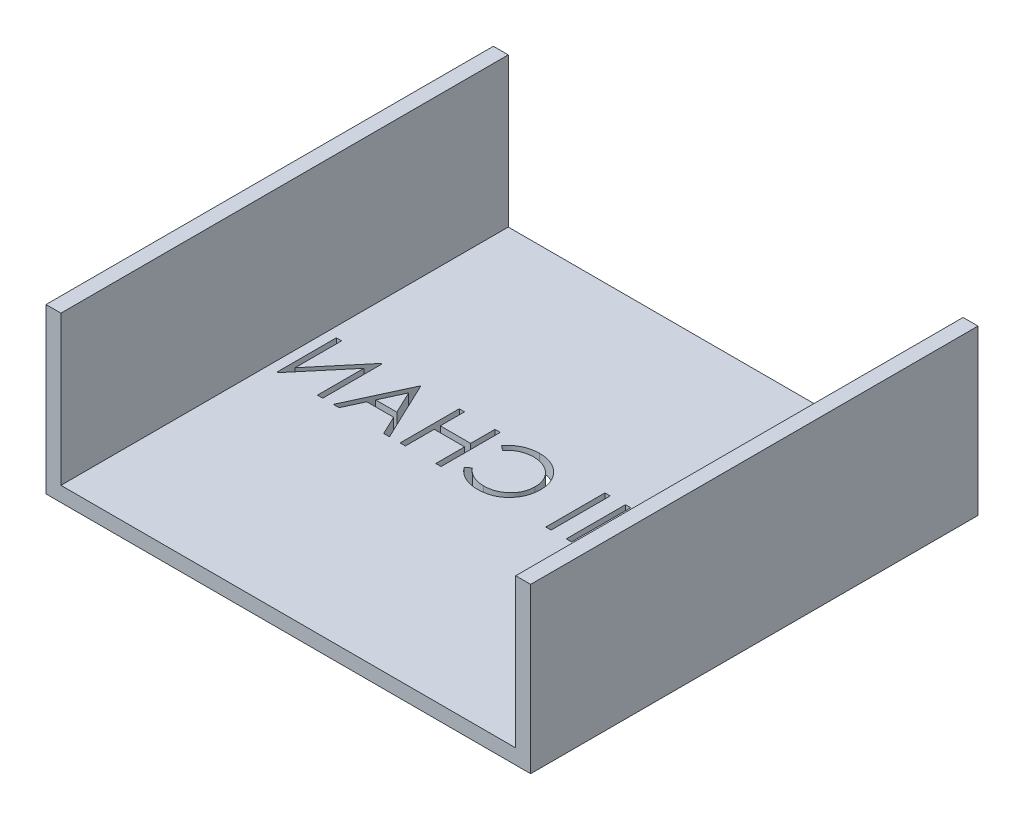
from build123d import *

# Parameters (mm, degrees)
SKETCH1_W           = 65
SKETCH1_H           = 60
BOSS_EXTRUDE1_DEPTH = 2
BOSS_EXTRUDE2_DEPTH = 20
SKETCH4_W           = 0.712339743
SKETCH4_H           = 7.9375
SKETCH4_W_2         = 0.712339744
CUT_EXTRUDE1_DEPTH  = 20


with BuildPart() as part:
    # Sketch1 → Boss-Extrude1 (new body)
    with BuildSketch(Plane(origin=(0, 0, 0), x_dir=(1, 0, 0), z_dir=(0, 1, 0))):
        Rectangle(SKETCH1_W, SKETCH1_H)
    extrude(amount=BOSS_EXTRUDE1_DEPTH)

    # Sketch3 → Boss-Extrude2 (add)
    with BuildSketch(Plane(origin=(0, 2, 0), x_dir=(1, 0, 0), z_dir=(0, 1, 0))):
        Polygon((-30.5, 30), (-32.5, 30), (-32.5, -30), (-30.5, -30), (-30.5, 0), align=None)
        Polygon((32.5, 30), (30.5, 30), (30.5, 0), (30.5, -30), (32.5, -30), align=None)
    extrude(amount=BOSS_EXTRUDE2_DEPTH)

    # Sketch4 → Cut-Extrude1 (cut)
    with BuildSketch(Plane(origin=(0, 0, 0), x_dir=(-1, 0, 0), z_dir=(0, -1, 0))):
        with BuildLine():
            add(Edge.make_bspline(
                [(-24.309282093, 5.81367782), (-24.162306567, 5.809955179), (-23.873634508, 5.802643606), (-23.449375365, 5.746674924), (-23.044347203, 5.649847879), (-22.655250638, 5.520890758), (-22.28673978, 5.348863849), (-21.936040863, 5.14093503), (-21.60398831, 4.894925918), (-21.295057677, 4.612738207), (-21.012353522, 4.305707874), (-20.763284101, 3.978052614), (-20.554545328, 3.631753544), (-20.383127561, 3.267851304), (-20.248646785, 2.887168876), (-20.15584824, 2.487676763), (-20.096570649, 2.071963376), (-20.089640582, 1.788420308), (-20.086125042, 1.644582267)],
                knots=[0, 0, 0, 0, 0.000440855, 0.000865876, 0.001280862, 0.001688649, 0.002093439, 0.002498389, 0.0029099, 0.003330887, 0.003751771, 0.004160416, 0.004563453, 0.004962482, 0.00536529, 0.005772174, 0.006191104, 0.006622429, 0.006622429, 0.006622429, 0.006622429], degree=3))
            add(Edge.make_bspline(
                [(-20.086125042, 1.644582267), (-20.089640067, 1.501803773), (-20.09656859, 1.220370819), (-20.155915639, 0.807295508), (-20.248990764, 0.410214822), (-20.381878725, 0.029791645), (-20.552479363, -0.33437533), (-20.762608055, -0.681327886), (-21.010124729, -1.011179767), (-21.291808124, -1.320317418), (-21.598878344, -1.603793825), (-21.928239842, -1.850806275), (-22.272485407, -2.063359201), (-22.636044923, -2.23295789), (-23.014096793, -2.368512066), (-23.410024561, -2.46093321), (-23.821972996, -2.520548468), (-24.102894737, -2.527394031), (-24.24568033, -2.530873462)],
                knots=[0, 0, 0, 0, 0.000428147, 0.000843928, 0.001249264, 0.001650047, 0.002050514, 0.002453552, 0.002864737, 0.003285724, 0.003706608, 0.004116522, 0.004519026, 0.004918054, 0.005317864, 0.005721654, 0.00613586, 0.006564007, 0.006564007, 0.006564007, 0.006564007], degree=3))
            add(Edge.make_bspline(
                [(-24.24568033, -2.530873462), (-24.389517625, -2.527359674), (-24.673059222, -2.520433063), (-25.089294999, -2.461057377), (-25.489067739, -2.368208348), (-25.871234214, -2.235517306), (-26.236007537, -2.064028229), (-26.584101117, -1.854921869), (-26.914117755, -1.606802102), (-27.223321358, -1.325210049), (-27.506234718, -1.01866028), (-27.752885445, -0.69019688), (-27.962038827, -0.346263969), (-28.132952099, 0.014092916), (-28.26826257, 0.389131723), (-28.360575282, 0.781354163), (-28.420301459, 1.188524114), (-28.427184057, 1.465753544), (-28.430676324, 1.606421209)],
                knots=[0, 0, 0, 0, 0.000431324, 0.000850255, 0.001258686, 0.00166097, 0.002061437, 0.002465837, 0.002877022, 0.003298009, 0.003718893, 0.004126581, 0.004528258, 0.004924412, 0.005321226, 0.005721923, 0.006131405, 0.006553199, 0.006553199, 0.006553199, 0.006553199], degree=3))
            add(Edge.make_bspline(
                [(-28.430676324, 1.606421209), (-28.429463847, 1.700838155), (-28.427054189, 1.888480935), (-28.398044458, 2.167124832), (-28.355949171, 2.441287574), (-28.295619834, 2.710189545), (-28.216717303, 2.973172493), (-28.12361717, 3.232050116), (-28.009907163, 3.484198918), (-27.881363551, 3.730813395), (-27.737894808, 3.968049182), (-27.57942659, 4.192293951), (-27.411524951, 4.405429425), (-27.227457969, 4.601932452), (-27.033292102, 4.787519494), (-26.825877566, 4.959338513), (-26.606479976, 5.118938848), (-26.374155293, 5.262767122), (-26.134628134, 5.392849445), (-25.887711156, 5.504477571), (-25.63675786, 5.600285604), (-25.380592855, 5.677938904), (-25.11989639, 5.7392437), (-24.854099485, 5.780988948), (-24.583413894, 5.810072669), (-24.401052509, 5.812470933), (-24.309282093, 5.81367782)],
                knots=[0, 0, 0, 0, 0.000283139, 0.000562707, 0.000839544, 0.00111497, 0.001388652, 0.001662791, 0.001939668, 0.002217749, 0.002496714, 0.002770654, 0.003041079, 0.003309984, 0.00357766, 0.003846392, 0.004117372, 0.00439092, 0.004665533, 0.004934509, 0.00520324, 0.005470831, 0.005736958, 0.006005943, 0.006277599, 0.006552792, 0.006552792, 0.006552792, 0.006552792], degree=3))
        make_face()
        with BuildLine():
            add(Edge.make_bspline(
                [(-24.274301123, 4.999575256), (-24.349627167, 4.998657022), (-24.499559133, 4.996829334), (-24.722454421, 4.972754408), (-24.942418271, 4.938441981), (-25.15949611, 4.889498175), (-25.372779659, 4.822813984), (-25.584256977, 4.746067639), (-25.791999617, 4.652584094), (-25.995321759, 4.546963854), (-26.192432733, 4.430058265), (-26.378425824, 4.300854437), (-26.553782535, 4.162382358), (-26.718073514, 4.01431887), (-26.870816351, 3.855909952), (-27.015017371, 3.689557105), (-27.1448966, 3.510505495), (-27.263926391, 3.323610465), (-27.370442743, 3.129115451), (-27.465160601, 2.929068085), (-27.542639692, 2.721836545), (-27.605827581, 2.509669081), (-27.658214652, 2.292901717), (-27.691402301, 2.06989006), (-27.71574176, 1.841754716), (-27.71746498, 1.687581583), (-27.71833658, 1.609601297)],
                knots=[0, 0, 0, 0, 0.000225876, 0.000449592, 0.000671789, 0.000893582, 0.001116398, 0.00134177, 0.001568115, 0.001799246, 0.002028852, 0.00225512, 0.002478117, 0.002698773, 0.002918043, 0.003137935, 0.003358648, 0.003580965, 0.003802278, 0.0040235, 0.004244401, 0.004465235, 0.004687386, 0.004912724, 0.005141187, 0.00537501, 0.00537501, 0.00537501, 0.00537501], degree=3))
            add(Edge.make_bspline(
                [(-27.71833658, 1.609601297), (-27.715445375, 1.494933404), (-27.709757481, 1.269346183), (-27.659960849, 0.938764857), (-27.583257443, 0.621064636), (-27.470188058, 0.317983878), (-27.328785771, 0.026917379), (-27.154099788, -0.249552787), (-26.947137219, -0.511501341), (-26.71204315, -0.75709954), (-26.45504344, -0.981267704), (-26.182145999, -1.17803472), (-25.896274425, -1.344518679), (-25.596683233, -1.48014804), (-25.28497185, -1.587621195), (-24.959131689, -1.661278091), (-24.621333326, -1.70975457), (-24.391076304, -1.714409927), (-24.274301123, -1.716770898)],
                knots=[0, 0, 0, 0, 0.000343817, 0.000676395, 0.001000721, 0.001322681, 0.001644817, 0.001969941, 0.002301712, 0.002644723, 0.002988456, 0.003323386, 0.003652556, 0.003979169, 0.004308524, 0.004639841, 0.004980069, 0.005330172, 0.005330172, 0.005330172, 0.005330172], degree=3))
            add(Edge.make_bspline(
                [(-24.274301123, -1.716770898), (-24.195811718, -1.715692522), (-24.040143653, -1.713553779), (-23.808605594, -1.692012137), (-23.581238828, -1.657468433), (-23.358362265, -1.607732839), (-23.140228853, -1.545486496), (-22.925928139, -1.471536827), (-22.71774273, -1.379277668), (-22.513046313, -1.277342135), (-22.317111979, -1.161136778), (-22.130069254, -1.036318117), (-21.956632657, -0.898049995), (-21.792464584, -0.752186385), (-21.639094646, -0.59578623), (-21.497559986, -0.42905287), (-21.368337186, -0.250933879), (-21.249352595, -0.064322334), (-21.143209481, 0.130704882), (-21.05072831, 0.331477545), (-20.972269261, 0.537501275), (-20.908931402, 0.749073231), (-20.859298302, 0.965791585), (-20.825099197, 1.187946512), (-20.801176846, 1.415093592), (-20.799373724, 1.56872698), (-20.798464785, 1.646172311)],
                knots=[0, 0, 0, 0, 0.000235412, 0.000466894, 0.000696945, 0.000924943, 0.001151434, 0.001377226, 0.001604385, 0.001834068, 0.002062863, 0.002287335, 0.0025081, 0.002727693, 0.002945825, 0.003164685, 0.003383176, 0.003605493, 0.003828201, 0.004048753, 0.004268168, 0.004489001, 0.004710793, 0.004934561, 0.005163024, 0.005395258, 0.005395258, 0.005395258, 0.005395258], degree=3))
            add(Edge.make_bspline(
                [(-20.798464785, 1.646172311), (-20.799374452, 1.72308783), (-20.801178944, 1.875663929), (-20.825087771, 2.101226856), (-20.859334433, 2.321783247), (-20.908689146, 2.536467229), (-20.972302887, 2.745333527), (-21.050742011, 2.948185972), (-21.143237244, 3.145780272), (-21.24939161, 3.337628052), (-21.368716781, 3.521720762), (-21.499105512, 3.697711947), (-21.642809069, 3.862296557), (-21.795721661, 4.019537738), (-21.961662776, 4.166081881), (-22.139880729, 4.301977597), (-22.328211926, 4.430504487), (-22.527618335, 4.546449958), (-22.733412659, 4.653525093), (-22.944581814, 4.745262189), (-23.158733522, 4.823213246), (-23.375323205, 4.889699934), (-23.596173888, 4.938250288), (-23.819793286, 4.97278533), (-24.045872015, 4.996820955), (-24.19791646, 4.998654242), (-24.274301123, 4.999575256)],
                knots=[0, 0, 0, 0, 0.000230644, 0.000457525, 0.000679722, 0.000899965, 0.001117754, 0.001334199, 0.001551867, 0.001771788, 0.001991427, 0.002209582, 0.002428269, 0.002646401, 0.002867182, 0.003091711, 0.003318391, 0.003550734, 0.003783277, 0.004013987, 0.004240851, 0.00446671, 0.004693156, 0.004918494, 0.005145375, 0.00537443, 0.00537443, 0.00537443, 0.00537443], degree=3))
        make_face(mode=Mode.SUBTRACT)
        Polygon((-18.457919914, -2.327347821), (-18.457919914, 5.610152179), (-18.308455771, 5.610152179), (-13.064490426, -0.637130974), (-13.064490426, 5.610152179), (-12.352150683, 5.610152179), (-12.352150683, -2.327347821), (-12.514335178, -2.327347821), (-17.74558017, 3.905624935), (-17.74558017, -2.327347821), align=None)
        with Locations((-9.960724401, 1.641402179)):
            Rectangle(SKETCH4_W, SKETCH4_H)
        with Locations((-7.213128247, 1.641402179)):
            Rectangle(SKETCH4_W_2, SKETCH4_H)
        with BuildLine():
            Line((5.558105728, 4.15367181), (4.934808452, 3.676658589))
            add(Edge.make_bspline(
                [(4.934808452, 3.676658589), (4.890345098, 3.729649271), (4.802017852, 3.834916205), (4.659915732, 3.9827341), (4.511820935, 4.121221389), (4.357790071, 4.251037795), (4.195050639, 4.367643674), (4.027544899, 4.47711564), (3.852470761, 4.575240689), (3.610373077, 4.694219246), (3.293671707, 4.818375705), (2.894994126, 4.922477676), (2.47881717, 4.988747128), (2.1948869, 4.995924536), (2.050468508, 4.999575256)],
                knots=[0, 0, 0, 0, 0.000207475, 0.000412153, 0.000614644, 0.000815582, 0.001015953, 0.001214861, 0.001415635, 0.00161759, 0.002023886, 0.002433479, 0.002851754, 0.00328474, 0.00328474, 0.00328474, 0.00328474], degree=3))
            add(Edge.make_bspline(
                [(2.050468508, 4.999575256), (1.970904597, 4.998659126), (1.812515203, 4.99683537), (1.577455272, 4.97277539), (1.346784603, 4.938958896), (1.120653242, 4.888781824), (0.899349032, 4.82534392), (0.681425192, 4.749539856), (0.470036867, 4.655752987), (0.262259791, 4.552093183), (0.063189081, 4.435009514), (-0.125167903, 4.307298876), (-0.302124187, 4.17039039), (-0.467819754, 4.023770917), (-0.622423994, 3.868100756), (-0.764816645, 3.70172091), (-0.894504986, 3.525163302), (-1.014059668, 3.34075611), (-1.121131403, 3.149036476), (-1.210779522, 2.949294798), (-1.290166139, 2.744951564), (-1.352984064, 2.533698039), (-1.402705736, 2.317020695), (-1.437013115, 2.094338015), (-1.460799469, 1.866115206), (-1.462614156, 1.711426229), (-1.463528888, 1.633451958)],
                knots=[0, 0, 0, 0, 0.000238591, 0.000474968, 0.000708163, 0.000937714, 0.001169228, 0.001398548, 0.001629257, 0.001862496, 0.002094838, 0.002321519, 0.002544788, 0.00276557, 0.002984817, 0.003202467, 0.003421899, 0.003641538, 0.003861459, 0.004079904, 0.004297833, 0.004518666, 0.004740458, 0.004964226, 0.005194271, 0.005428094, 0.005428094, 0.005428094, 0.005428094], degree=3))
            add(Edge.make_bspline(
                [(-1.463528888, 1.633451958), (-1.460667263, 1.516132715), (-1.455048841, 1.285791942), (-1.405046369, 0.948401451), (-1.329061608, 0.625184922), (-1.215179854, 0.31816278), (-1.074756292, 0.023549182), (-0.897317763, -0.253671074), (-0.691812401, -0.517687212), (-0.455332914, -0.762259611), (-0.195876867, -0.985674667), (0.082497861, -1.182412593), (0.379097942, -1.346412415), (0.690648514, -1.482882866), (1.019547022, -1.587786516), (1.365202021, -1.661637296), (1.726861724, -1.709811527), (1.973988756, -1.714423641), (2.099759874, -1.716770898)],
                knots=[0, 0, 0, 0, 0.000351759, 0.000690633, 0.001021136, 0.001346082, 0.001671077, 0.001998395, 0.002331417, 0.00267328, 0.003017175, 0.003357288, 0.003693965, 0.0040322, 0.004376149, 0.004727635, 0.005091509, 0.005468621, 0.005468621, 0.005468621, 0.005468621], degree=3))
            add(Edge.make_bspline(
                [(2.099759874, -1.716770898), (2.238332044, -1.712940987), (2.511075223, -1.705402805), (2.911052711, -1.641541651), (3.293948108, -1.537996016), (3.65978201, -1.393084657), (4.007523083, -1.20470445), (4.337715509, -0.976336049), (4.650637999, -0.705807152), (4.838805014, -0.499243629), (4.934808452, -0.393854231)],
                knots=[0, 0, 0, 0, 0.000415516, 0.000817835, 0.001211659, 0.001603475, 0.001995472, 0.002395512, 0.002805811, 0.003233205, 0.003233205, 0.003233205, 0.003233205], degree=3))
            Line((4.934808452, -0.393854231), (5.558105728, -0.86609732))
            add(Edge.make_bspline(
                [(5.558105728, -0.86609732), (5.507945014, -0.930818452), (5.407863854, -1.059950706), (5.24580728, -1.241995476), (5.075089123, -1.413227842), (4.894441352, -1.572267269), (4.705942075, -1.722296146), (4.506206652, -1.859052085), (4.297860811, -1.984443912), (4.081610475, -2.099258545), (3.857685406, -2.201124444), (3.62635392, -2.288332096), (3.388613151, -2.363454613), (3.14445223, -2.425258113), (2.89336471, -2.473497892), (2.63625667, -2.505746083), (2.372573203, -2.527839354), (2.194679266, -2.52985302), (2.104530006, -2.530873462)],
                knots=[0, 0, 0, 0, 0.000245594, 0.000490011, 0.000730618, 0.000970546, 0.001211672, 0.001452924, 0.001696165, 0.001940846, 0.002187056, 0.002433641, 0.002682065, 0.002934662, 0.003188815, 0.003448558, 0.003711728, 0.00398211, 0.00398211, 0.00398211, 0.00398211], degree=3))
            add(Edge.make_bspline(
                [(2.104530006, -2.530873462), (2.019159547, -2.530279301), (1.850350036, -2.529104419), (1.601115367, -2.510072183), (1.358478282, -2.484105815), (1.123132255, -2.445007661), (0.89379299, -2.398869604), (0.672539522, -2.337022289), (0.45719467, -2.267741144), (0.248623612, -2.186313763), (0.046648935, -2.094428849), (-0.148077923, -1.990580135), (-0.335467403, -1.875640906), (-0.51736184, -1.752144722), (-0.691074217, -1.61612477), (-0.858109891, -1.469470081), (-1.019405506, -1.312674949), (-1.11919731, -1.199611264), (-1.169370735, -1.142764989)],
                knots=[0, 0, 0, 0, 0.000256042, 0.00050629, 0.000749484, 0.000987885, 0.001221767, 0.001450893, 0.001676663, 0.001900187, 0.002122185, 0.002341985, 0.00256178, 0.002781413, 0.003001196, 0.003223171, 0.003448048, 0.003675441, 0.003675441, 0.003675441, 0.003675441], degree=3))
            add(Edge.make_bspline(
                [(-1.169370735, -1.142764989), (-1.249733712, -1.044019792), (-1.409489454, -0.847721538), (-1.613881629, -0.529572974), (-1.788841263, -0.197404), (-1.930300941, 0.150530481), (-2.040887854, 0.513449734), (-2.117498778, 0.891536705), (-2.167281881, 1.284438288), (-2.172974858, 1.551675291), (-2.175868631, 1.687513457)],
                knots=[0, 0, 0, 0, 0.000381693, 0.000758779, 0.001132168, 0.001506572, 0.001883818, 0.002268629, 0.002662677, 0.003070039, 0.003070039, 0.003070039, 0.003070039], degree=3))
            add(Edge.make_bspline(
                [(-2.175868631, 1.687513457), (-2.172341675, 1.830287432), (-2.165402607, 2.111186314), (-2.106447857, 2.523423673), (-2.011608801, 2.918374167), (-1.876905143, 3.295300516), (-1.706123364, 3.656185259), (-1.495152294, 3.998271562), (-1.246442882, 4.323747162), (-0.961945719, 4.627673473), (-0.649962655, 4.905575219), (-0.315864631, 5.150064288), (0.039694427, 5.353530797), (0.412797412, 5.52361138), (0.806238154, 5.654340788), (1.219177224, 5.74585605), (1.650838691, 5.802818082), (1.945348121, 5.810019), (2.094989742, 5.81367782)],
                knots=[0, 0, 0, 0, 0.000428147, 0.000842353, 0.001246515, 0.001644827, 0.002040981, 0.002442129, 0.002848241, 0.003267871, 0.003689098, 0.00410001, 0.004507471, 0.004915936, 0.005328245, 0.005748715, 0.006183196, 0.006631994, 0.006631994, 0.006631994, 0.006631994], degree=3))
            add(Edge.make_bspline(
                [(2.094989742, 5.81367782), (2.186190419, 5.812584399), (2.366712976, 5.810420083), (2.63375917, 5.789315083), (2.89375159, 5.75413244), (3.146869352, 5.70624421), (3.394343857, 5.646809749), (3.634283689, 5.56938443), (3.868096782, 5.480855153), (4.094308521, 5.378895775), (4.311833554, 5.264444415), (4.520604134, 5.138769697), (4.718961938, 5.002027424), (4.908302719, 4.85538058), (5.085459127, 4.695726704), (5.255461051, 4.527457156), (5.412535282, 4.345725091), (5.509493421, 4.217806759), (5.558105728, 4.15367181)],
                knots=[0, 0, 0, 0, 0.000273562, 0.000541487, 0.000803015, 0.001060292, 0.001314048, 0.001565983, 0.001816106, 0.002063765, 0.002309852, 0.002553093, 0.002794345, 0.003032257, 0.003270997, 0.003509355, 0.003749431, 0.003990829, 0.003990829, 0.003990829, 0.003990829], degree=3))
        make_face()
        Polygon((7.186310856, 5.610152179), (7.898650599, 5.610152179), (7.898650599, 2.353741922), (11.96916342, 2.353741922), (11.96916342, 5.610152179), (12.681503163, 5.610152179), (12.681503163, -2.327347821), (11.96916342, -2.327347821), (11.96916342, 1.539639358), (7.898650599, 1.539639358), (7.898650599, -2.327347821), (7.186310856, -2.327347821), align=None)
        Polygon((17.97316983, 5.610152179), (21.636631369, -2.327347821), (20.862279906, -2.327347821), (19.688827382, 0.216722692), (16.090557651, 0.216722692), (14.883714201, -2.327347821), (14.106182651, -2.327347821), (17.87140701, 5.610152179), align=None)
        Polygon((17.914338199, 4.063039298), (16.47693836, 1.030825256), (19.313576982, 1.030825256), align=None, mode=Mode.SUBTRACT)
        Polygon((23.061310856, -2.327347821), (23.061310856, 5.610152179), (23.210774998, 5.610152179), (28.454740343, -0.637130974), (28.454740343, 5.610152179), (29.167080086, 5.610152179), (29.167080086, -2.327347821), (29.004895591, -2.327347821), (23.773650599, 3.905624935), (23.773650599, -2.327347821), align=None)
    extrude(amount=-CUT_EXTRUDE1_DEPTH, mode=Mode.SUBTRACT)


solid = part.part
